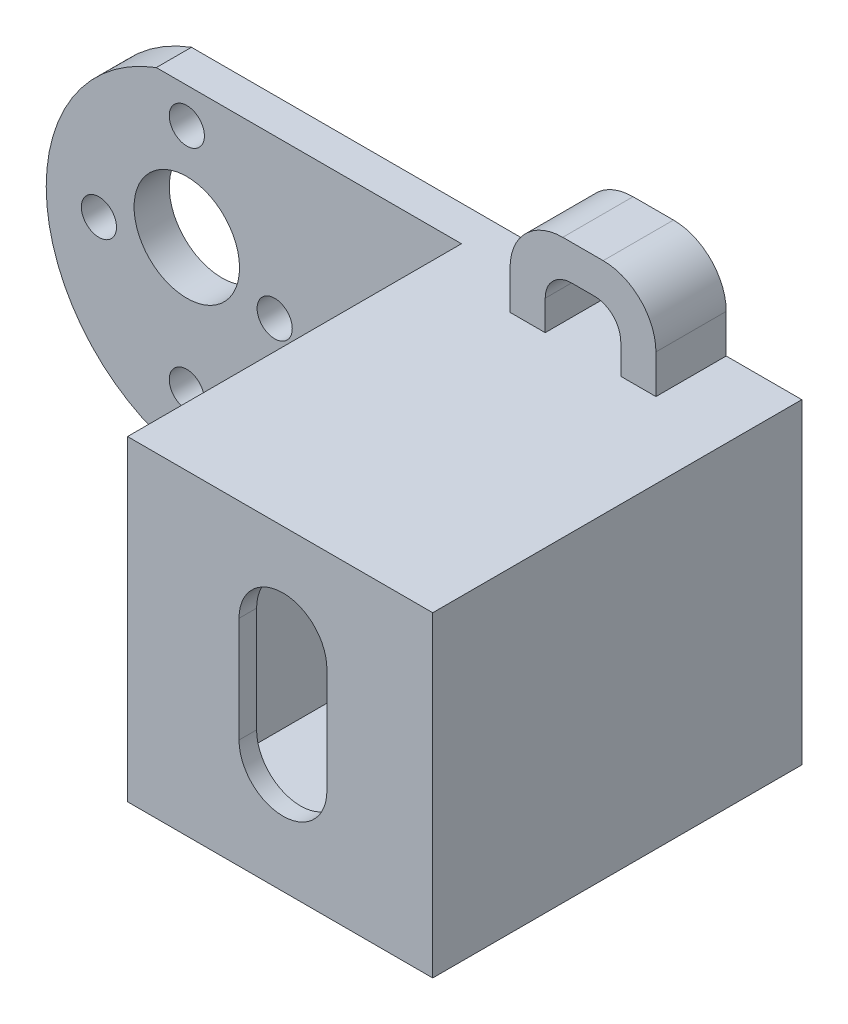
from build123d import *

# Parameters (mm, degrees)
SKETCH2_R            = 1
SKETCH2_R_2          = 3
BOSS_EXTRUDE2_DEPTH  = 2
SKETCH3_W            = 10.8
SKETCH3_H            = 12.5
CUT_EXTRUDE1_DEPTH   = 3
SKETCH4_W            = 17.364181201
SKETCH4_H            = 18
BOSS_EXTRUDE3_DEPTH  = 19
SKETCH5_W            = 10.8
SKETCH5_H            = 12.5
CUT_EXTRUDE2_DEPTH   = 18
BOSS_EXTRUDE4_DEPTH  = 4
FILLET1_R            = 1.5
FILLET2_R            = 3
FILLET1_OF_MIRROR1_R = 1.5
FILLET2_OF_MIRROR1_R = 3
CUT_EXTRUDE3_DEPTH   = 10


with BuildPart() as part:
    # Sketch2 → Boss-Extrude2 (new body)
    with BuildSketch(Plane.XY):
        with BuildLine():
            Line((-18.735484911, 68.428926153), (15.992877491, 68.428926153))
            Line((15.992877491, 68.428926153), (15.992877491, 50.428926153))
            Line((15.992877491, 50.428926153), (-18.735484911, 50.428926153))
            ThreePointArc((-18.735484911, 50.428926153), (-25.000050177, 59.428926153), (-18.735484911, 68.428926153))
        make_face()
        with Locations((-17, 53.428926153)):
            Circle(SKETCH2_R, mode=Mode.SUBTRACT)
        with Locations((-17, 60.928926153)):
            Circle(SKETCH2_R_2, mode=Mode.SUBTRACT)
        with Locations((-22, 59.428926153)):
            Circle(SKETCH2_R, mode=Mode.SUBTRACT)
        with Locations((-17, 66.428926153)):
            Circle(SKETCH2_R, mode=Mode.SUBTRACT)
        with Locations((-12, 59.428926153)):
            Circle(SKETCH2_R, mode=Mode.SUBTRACT)
    extrude(amount=BOSS_EXTRUDE2_DEPTH)

    # Sketch3 → Cut-Extrude1 (cut, through all)
    with BuildSketch(Plane.XY.offset(2)):
        with Locations((7.592877491, 59.428926153)):
            Rectangle(SKETCH3_W, SKETCH3_H)
    extrude(amount=-CUT_EXTRUDE1_DEPTH, mode=Mode.SUBTRACT)

    # Sketch4 → Boss-Extrude3 (add)
    with BuildSketch(Plane.XY.offset(2)):
        with Locations((7.310786891, 59.428926153)):
            Rectangle(SKETCH4_W, SKETCH4_H)
    extrude(amount=BOSS_EXTRUDE3_DEPTH)

    # Sketch5 → Cut-Extrude2 (cut)
    with BuildSketch(Plane(origin=(0, 0, 2), x_dir=(-1, 0, 0), z_dir=(0, 0, -1))):
        with Locations((-7.592877491, 59.428926153)):
            Rectangle(SKETCH5_W, SKETCH5_H)
    extrude(amount=-CUT_EXTRUDE2_DEPTH, mode=Mode.SUBTRACT)

    # Sketch7 → Boss-Extrude4 (add)
    with BuildSketch(Plane(origin=(0, 0, 0), x_dir=(-1, 0, 0), z_dir=(0, 0, -1))):
        Polygon((-11.692877491, 68.428926153), (-9.692877491, 68.428926153), (-9.692877491, 71.628926153), (-5.392877491, 71.628926153), (-5.392877491, 68.428926153), (-3.392877491, 68.428926153), (-3.392877491, 73.628926153), (-11.692877491, 73.628926153), align=None)
    boss_extrude4 = extrude(amount=-BOSS_EXTRUDE4_DEPTH)

    # Fillet1
    fillet1_edges = [part.edges().sort_by_distance(p)[0] for p in [
        (5.392877491, 71.628926153, 2),
        (9.692877491, 71.628926153, 2),
    ]]
    fillet(fillet1_edges, radius=FILLET1_R)

    # Fillet2
    fillet2_edges = [part.edges().sort_by_distance(p)[0] for p in [
        (3.392877491, 73.628926153, 2),
        (11.692877491, 73.628926153, 2),
    ]]
    fillet(fillet2_edges, radius=FILLET2_R)

    # Mirror1: Boss-Extrude4 across plane
    add(boss_extrude4.mirror(Plane.ZX.offset(59.428926153)))

    # Fillet1 of Mirror1
    fillet1_of_mirror1_edges = [part.edges().sort_by_distance(p)[0] for p in [
        (5.392877491, 47.228926153, 2),
        (9.692877491, 47.228926153, 2),
    ]]
    fillet(fillet1_of_mirror1_edges, radius=FILLET1_OF_MIRROR1_R)

    # Fillet2 of Mirror1
    fillet2_of_mirror1_edges = [part.edges().sort_by_distance(p)[0] for p in [
        (3.392877491, 45.228926153, 2),
        (11.692877491, 45.228926153, 2),
    ]]
    fillet(fillet2_of_mirror1_edges, radius=FILLET2_OF_MIRROR1_R)

    # Sketch9 → Cut-Extrude3 (cut)
    with BuildSketch(Plane.XY.offset(21)):
        with BuildLine():
            Line((9.971454774, 62.64486165), (9.971454774, 56.64486165))
            ThreePointArc((9.971454774, 56.64486165), (7.471454774, 54.14486165), (4.971454774, 56.64486165))
            Line((4.971454774, 56.64486165), (4.971454774, 62.64486165))
            ThreePointArc((4.971454774, 62.64486165), (7.471454774, 65.14486165), (9.971454774, 62.64486165))
        make_face()
    extrude(amount=-CUT_EXTRUDE3_DEPTH, mode=Mode.SUBTRACT)


solid = part.part
